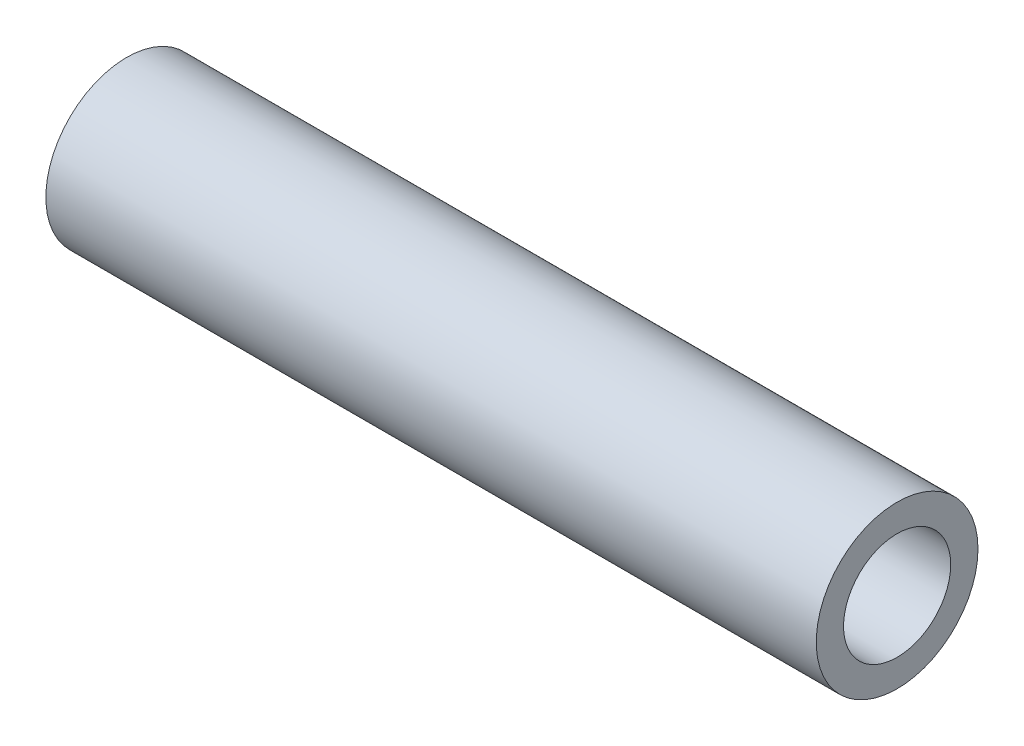
from build123d import *

# Parameters (mm, degrees)
SKETCH1_R           = 4
SKETCH1_R_2         = 2.65
BOSS_EXTRUDE1_DEPTH = 38.1


with BuildPart() as part:
    # Sketch1 → Boss-Extrude1 (new body)
    with BuildSketch(Plane(origin=(0, 0, 0), x_dir=(0, 0, -1), z_dir=(1, 0, 0))):
        Circle(SKETCH1_R)
        Circle(SKETCH1_R_2, mode=Mode.SUBTRACT)
    extrude(amount=BOSS_EXTRUDE1_DEPTH)


solid = part.part
